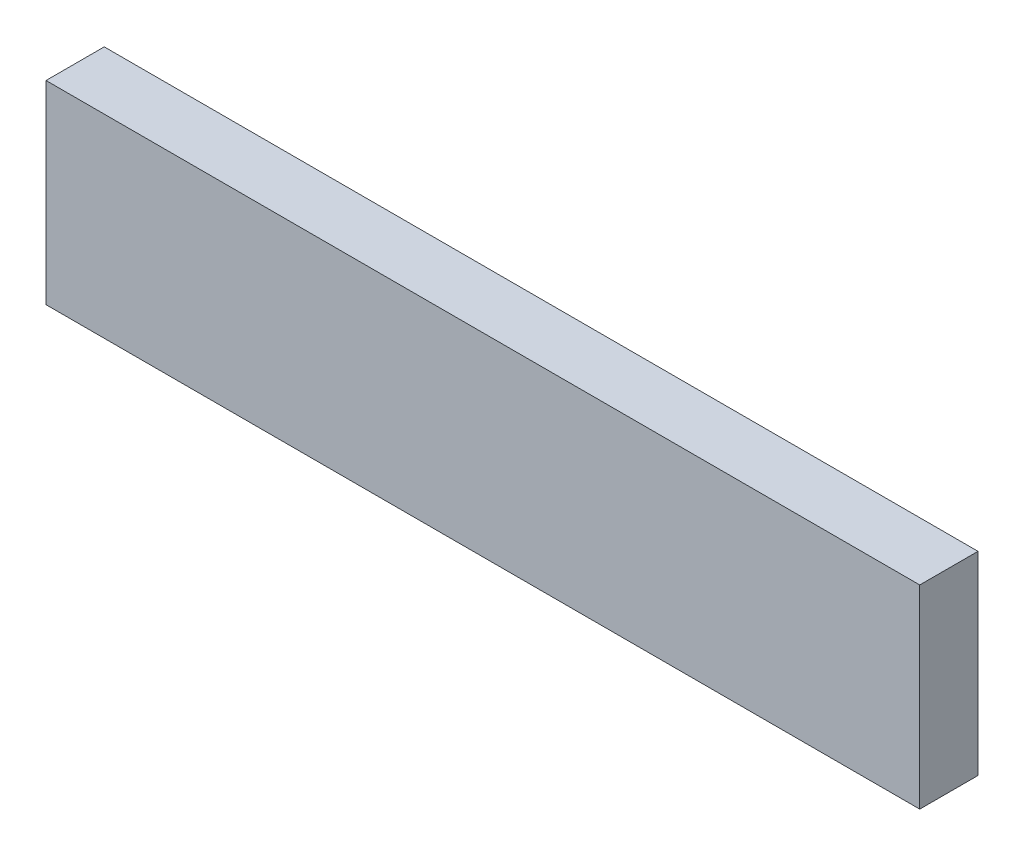
from build123d import *

# Parameters (mm, degrees)
SKETCH1_W           = 45
SKETCH1_H           = 10
BOSS_EXTRUDE1_DEPTH = 3


with BuildPart() as part:
    # Sketch1 → Boss-Extrude1 (new body)
    with BuildSketch(Plane.XY):
        Rectangle(SKETCH1_W, SKETCH1_H)
    extrude(amount=BOSS_EXTRUDE1_DEPTH)


solid = part.part
